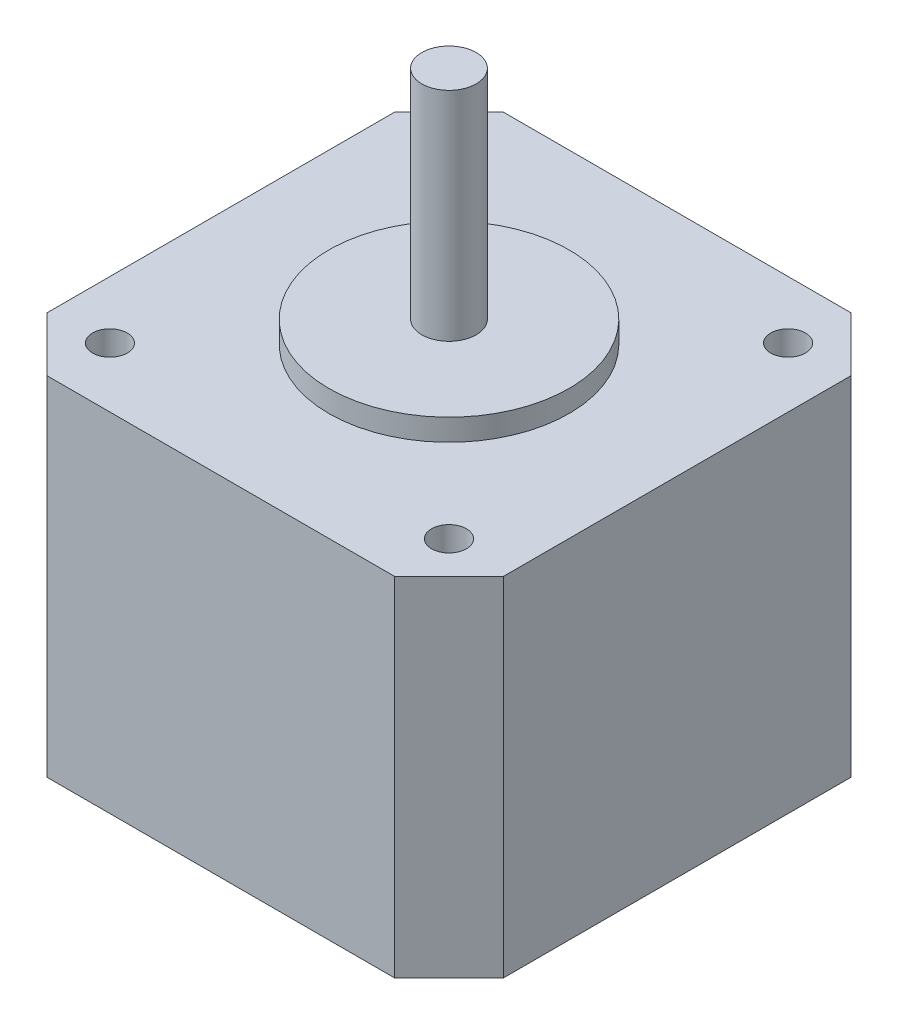
from build123d import *

# Parameters (mm, degrees)
SKETCH1_W           = 42
SKETCH1_H           = 42
BOSS_EXTRUDE1_DEPTH = 32
CHAMFER1_SIZE       = 5
SKETCH2_R           = 11.05
BOSS_EXTRUDE2_DEPTH = 2
SKETCH3_R           = 2.5
BOSS_EXTRUDE3_DEPTH = 20
SKETCH4_R           = 1.6
CUT_EXTRUDE1_DEPTH  = 5


with BuildPart() as part:
    # Sketch1 → Boss-Extrude1 (new body)
    with BuildSketch(Plane(origin=(0, 0, 0), x_dir=(1, 0, 0), z_dir=(0, 1, 0))):
        Rectangle(SKETCH1_W, SKETCH1_H)
    extrude(amount=BOSS_EXTRUDE1_DEPTH)

    # Chamfer1
    chamfer1_edges = [part.edges().sort_by_distance(p)[0] for p in [
        (21, 16, 21),
        (-21, 16, 21),
        (-21, 16, -21),
        (21, 16, -21),
    ]]
    chamfer(chamfer1_edges, length=CHAMFER1_SIZE)

    # Sketch2 → Boss-Extrude2 (add)
    with BuildSketch(Plane(origin=(0, 32, 0), x_dir=(1, 0, 0), z_dir=(0, 1, 0))):
        Circle(SKETCH2_R)
    extrude(amount=BOSS_EXTRUDE2_DEPTH)

    # Sketch3 → Boss-Extrude3 (add)
    with BuildSketch(Plane(origin=(0, 34, 0), x_dir=(1, 0, 0), z_dir=(0, 1, 0))):
        Circle(SKETCH3_R)
    extrude(amount=BOSS_EXTRUDE3_DEPTH)

    # Sketch4 → Cut-Extrude1 (cut)
    with BuildSketch(Plane(origin=(0, 32, 0), x_dir=(1, 0, 0), z_dir=(0, 1, 0))):
        with Locations((-15.7, 15.7)):
            Circle(SKETCH4_R)
        with Locations((15.5, 15.7)):
            Circle(SKETCH4_R)
        with Locations((15.5, -15.5)):
            Circle(SKETCH4_R)
        with Locations((-15.7, -15.5)):
            Circle(SKETCH4_R)
    extrude(amount=-CUT_EXTRUDE1_DEPTH, mode=Mode.SUBTRACT)


solid = part.part
